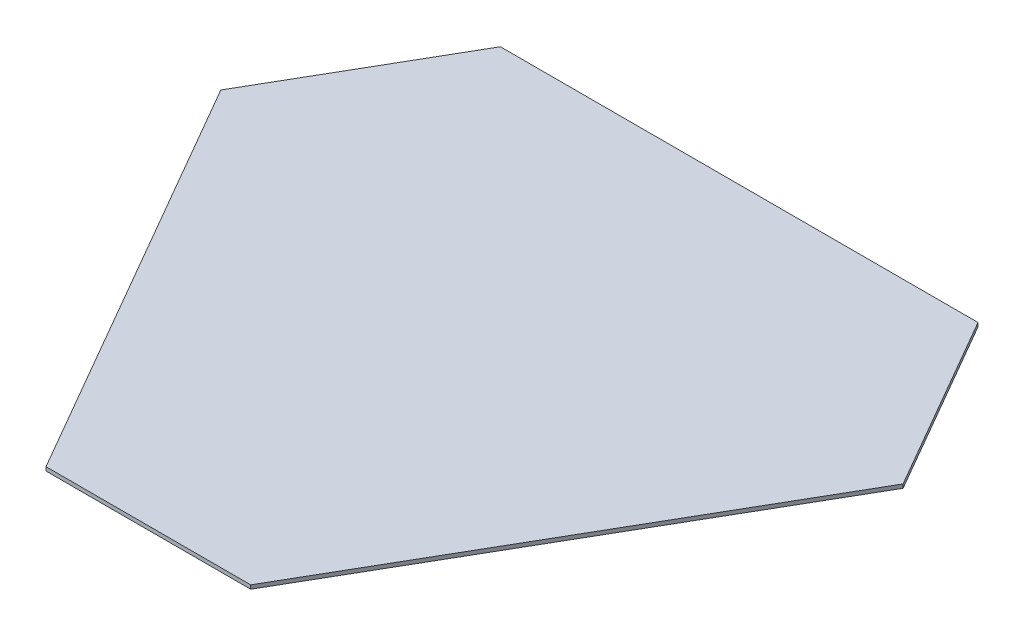
from build123d import *

# Parameters (mm, degrees)
BOSS_EXTRUDE1_DEPTH = 1.4


with BuildPart() as part:
    # Sketch1 → Boss-Extrude1 (new body)
    with BuildSketch(Plane(origin=(0, 0, 0), x_dir=(1, 0, 0), z_dir=(0, 1, 0))):
        Polygon((87.5, 93.819418743), (-87.5, 93.819418743), (-125, 28.867513459), (-37.5, -122.686932203), (37.5, -122.686932203), (125, 28.867513459), align=None)
    extrude(amount=BOSS_EXTRUDE1_DEPTH)


solid = part.part
